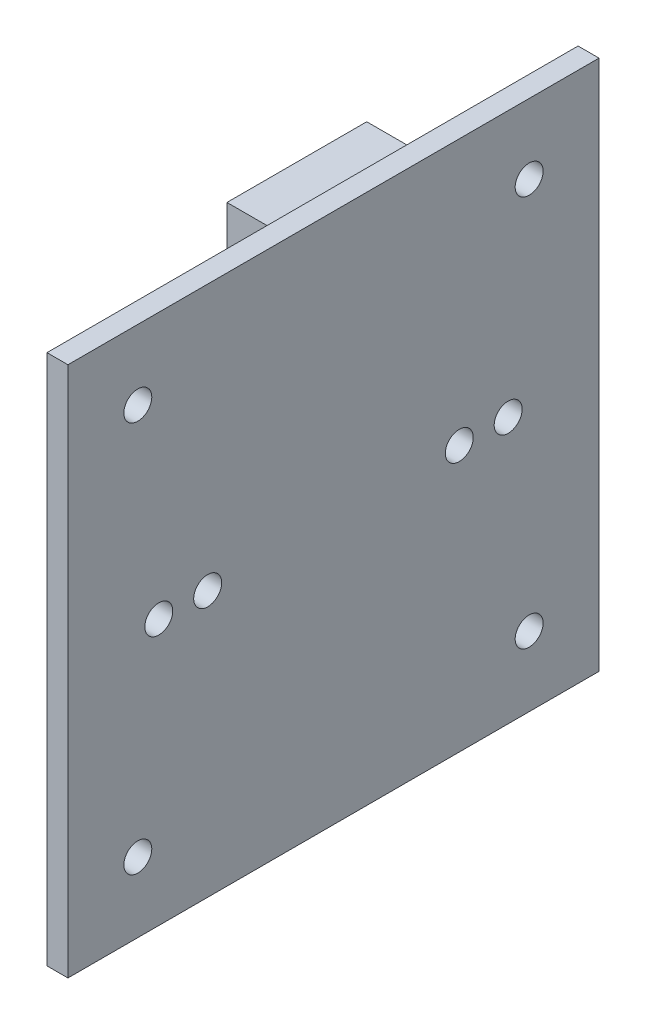
from build123d import *

# Parameters (mm, degrees)
SKETCH_1_W          = 38
SKETCH_1_H          = 38
EXTRUDE_1_DEPTH     = 1.5
SKETCH_2_R          = 1
CUT_EXTRUDE_1_DEPTH = 1.5
SKETCH_3_W          = 10
SKETCH_3_H          = 4
EXTRUDE_2_DEPTH     = 7
SKETCH_4_W          = 9.5
SKETCH_4_H          = 3.5
CUT_EXTRUDE_4_DEPTH = 5
SKETCH_6_R          = 1
CUT_EXTRUDE_6_DEPTH = 10


with BuildPart() as part:
    # 草图1 → 凸台-拉伸1 (new body)
    with BuildSketch(Plane(origin=(0, 0, 0), x_dir=(0, 0, -1), z_dir=(1, 0, 0))):
        Rectangle(SKETCH_1_W, SKETCH_1_H)
    extrude(amount=EXTRUDE_1_DEPTH)

    # 草图2 → 切除-拉伸1 (cut)
    with BuildSketch(Plane(origin=(1.5, 0, 0), x_dir=(0, 0, -1), z_dir=(1, 0, 0))):
        with Locations((-14, 14)):
            Circle(SKETCH_2_R)
        with Locations((-14, -14)):
            Circle(SKETCH_2_R)
        with Locations((14, -14)):
            Circle(SKETCH_2_R)
        with Locations((14, 14)):
            Circle(SKETCH_2_R)
        with Locations((-12.5, 0)):
            Circle(SKETCH_2_R)
        with Locations((12.5, 0)):
            Circle(SKETCH_2_R)
    extrude(amount=-CUT_EXTRUDE_1_DEPTH, mode=Mode.SUBTRACT)

    # 草图3 → 凸台-拉伸2 (add)
    with BuildSketch(Plane.ZY):
        with Locations((-5.878697065, 12.867552656)):
            Rectangle(SKETCH_3_W, SKETCH_3_H)
    extrude(amount=EXTRUDE_2_DEPTH)

    # 草图4 → 切除-拉伸4 (cut)
    with BuildSketch(Plane.ZY.offset(7)):
        with Locations((-5.878697065, 12.867552656)):
            Rectangle(SKETCH_4_W, SKETCH_4_H)
    extrude(amount=-CUT_EXTRUDE_4_DEPTH, mode=Mode.SUBTRACT)

    # 草图6 → 切除-拉伸6 (cut)
    with BuildSketch(Plane(origin=(1.5, 0, 0), x_dir=(0, 0, -1), z_dir=(1, 0, 0))):
        with Locations((-9, 0)):
            Circle(SKETCH_6_R)
        with Locations((9, 0)):
            Circle(SKETCH_6_R)
    extrude(amount=-CUT_EXTRUDE_6_DEPTH, mode=Mode.SUBTRACT)


solid = part.part
